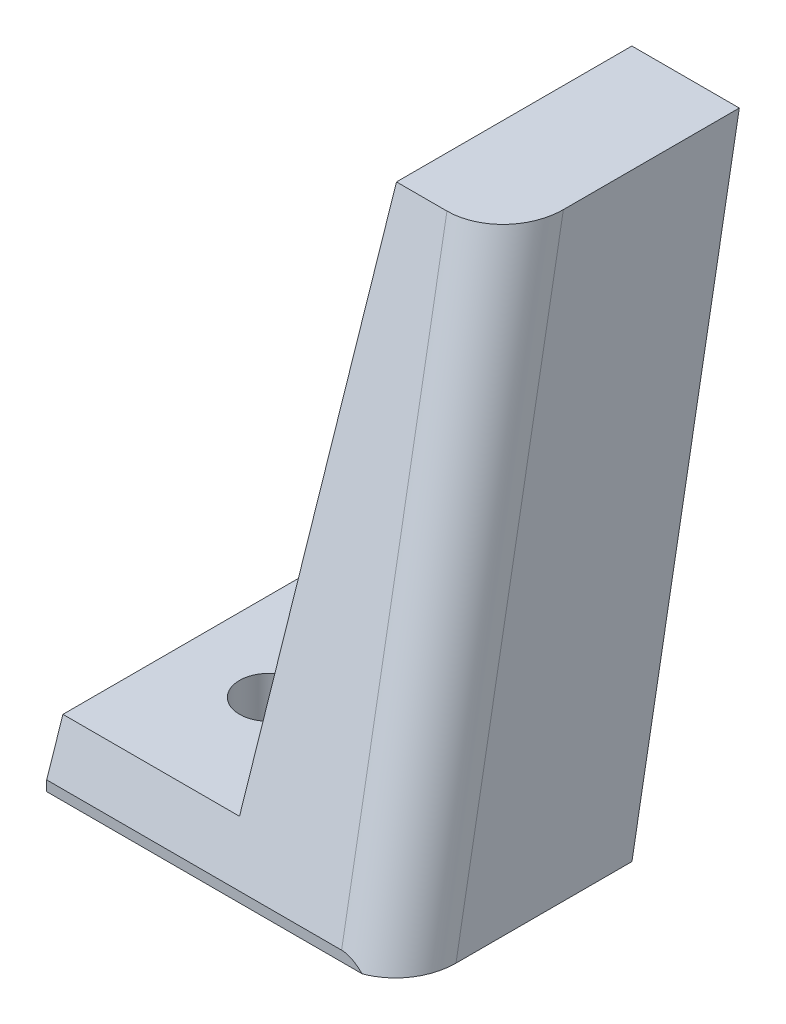
from build123d import *

# Parameters (mm, degrees)
EXTRUDE_1_DEPTH     = 50
CUT_EXTRUDE_3_DEPTH = 58
EXTRUDE_2_DEPTH     = 15
FILLET_1_R          = 5
SKETCH_6_R          = 2.5
CUT_EXTRUDE_4_DEPTH = 15


with BuildPart() as part:
    # Sketch 2 → Extrude 1 (new body)
    with BuildSketch(Plane.XY):
        Polygon((39.125, 45), (45, 0), (30, 0), (30, 45), align=None)
    extrude(amount=EXTRUDE_1_DEPTH)

    # Sketch 4 → Cut-Extrude 3 (cut)
    with BuildSketch(Plane(origin=(0, 0, 0), x_dir=(0, 0, -1), z_dir=(1, 0, 0))):
        Polygon((-50.288969981, 45), (-50.288969981, 0), (-35.288969981, 45), align=None)
        Polygon((0, 0), (-30.288969981, 0), (-15.293288519, 45), (0, 45), align=None)
    extrude(amount=CUT_EXTRUDE_3_DEPTH, mode=Mode.SUBTRACT)

    # Sketch 5 → Extrude 2 (add)
    with BuildSketch(Plane.ZY.offset(-30)):
        Polygon((30.288969981, 0), (50, 0), (50, 0.866909943), (48.622303314, 5), (28.622783152, 5), align=None)
    extrude(amount=EXTRUDE_2_DEPTH)

    # Fillet 1
    fillet_1_edges = [part.edges().sort_by_distance(p)[0] for p in [
        (42.005910045, 22.933454972, 42.644484991),
    ]]
    fillet(fillet_1_edges, radius=FILLET_1_R)

    # Sketch 6 → Cut-Extrude 4 (cut)
    with BuildSketch(Plane(origin=(0, 5, 0), x_dir=(1, 0, 0), z_dir=(0, 1, 0))):
        with Locations((22.5, -38.622543233)):
            Circle(SKETCH_6_R)
    extrude(amount=-CUT_EXTRUDE_4_DEPTH, mode=Mode.SUBTRACT)


solid = part.part
